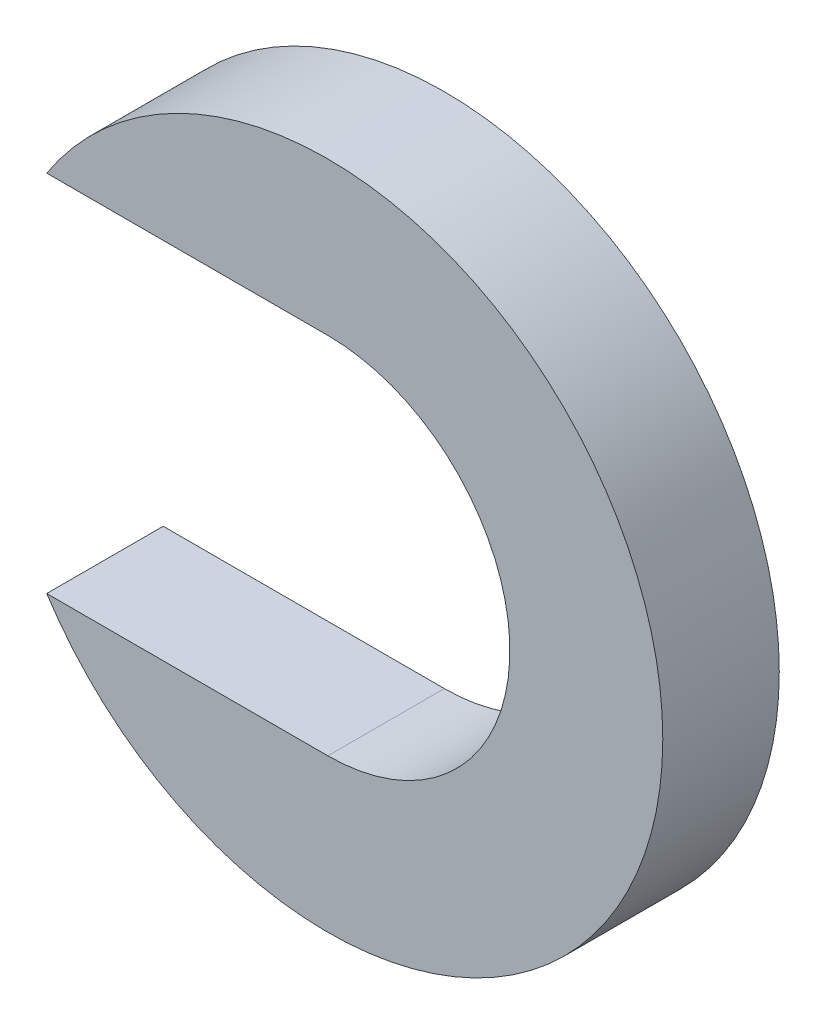
from build123d import *

# Parameters (mm, degrees)
EXTRUDE1_DEPTH = 3.175


with BuildPart() as part:
    # Sketch1 → Extrude1 (new body)
    with BuildSketch(Plane.XY):
        with BuildLine():
            Line((-7.662360285, -4.9609375), (0, -4.9609375))
            ThreePointArc((0, -4.9609375), (4.9609375, 0), (0, 4.9609375))
            Line((0, 4.9609375), (-7.662360285, 4.9609375))
            ThreePointArc((-7.662360285, 4.9609375), (9.128125, 0), (-7.662360285, -4.9609375))
        make_face()
    extrude(amount=EXTRUDE1_DEPTH)


solid = part.part
